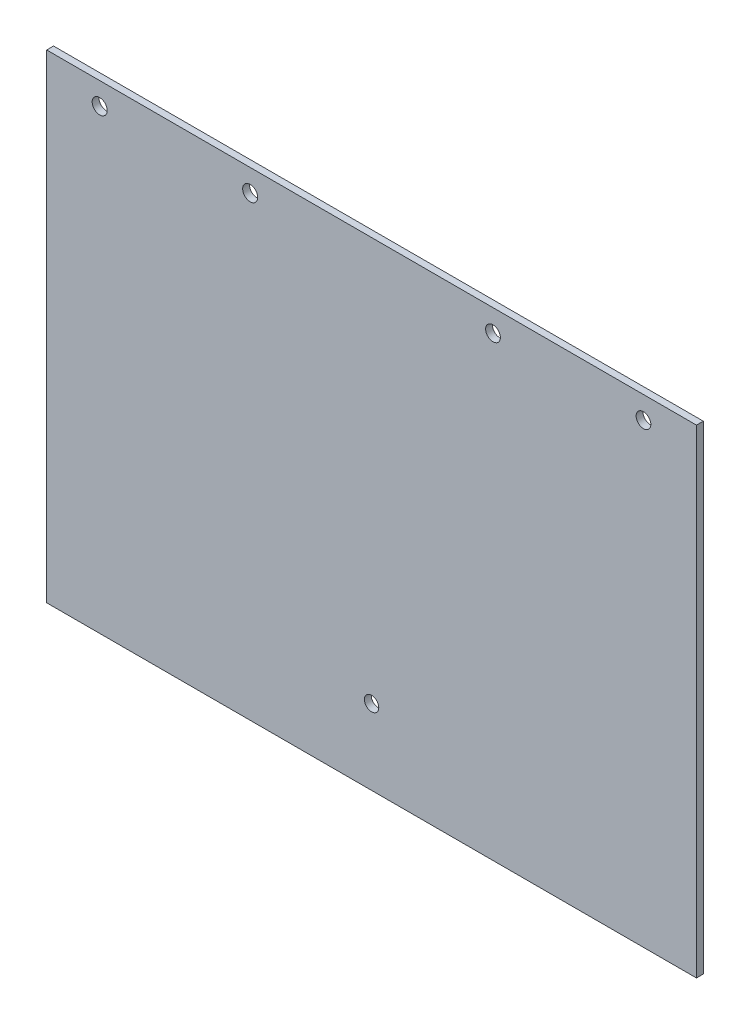
from build123d import *

# Parameters (mm, degrees)
SKETCH_1_W          = 190
SKETCH_1_H          = 140
EXTRUDE_1_DEPTH     = 2
SKETCH_2_R          = 2.15
SKETCH_2_R_2        = 2.2
CUT_EXTRUDE_1_DEPTH = 10
SKETCH_3_R          = 2.1
CUT_EXTRUDE_2_DEPTH = 10


with BuildPart() as part:
    # ｽｹｯﾁ1 → ﾎﾞｽ - 押し出し1 (new body)
    with BuildSketch(Plane.XY):
        Rectangle(SKETCH_1_W, SKETCH_1_H)
    extrude(amount=EXTRUDE_1_DEPTH)

    # ｽｹｯﾁ2 → ｶｯﾄ - 押し出し1 (cut)
    with BuildSketch(Plane.XY.offset(2)):
        with Locations((35.5, 63.5)):
            Circle(SKETCH_2_R)
        with Locations((79.5, 63.5)):
            Circle(SKETCH_2_R)
        with Locations((-35.5, 63.5)):
            Circle(SKETCH_2_R_2)
        with Locations((-79.5, 63.5)):
            Circle(SKETCH_2_R_2)
    extrude(amount=-CUT_EXTRUDE_1_DEPTH, mode=Mode.SUBTRACT)

    # ｽｹｯﾁ3 → ｶｯﾄ - 押し出し2 (cut)
    with BuildSketch(Plane.XY.offset(2)):
        with Locations((0, -48)):
            Circle(SKETCH_3_R)
    extrude(amount=-CUT_EXTRUDE_2_DEPTH, mode=Mode.SUBTRACT)


solid = part.part
